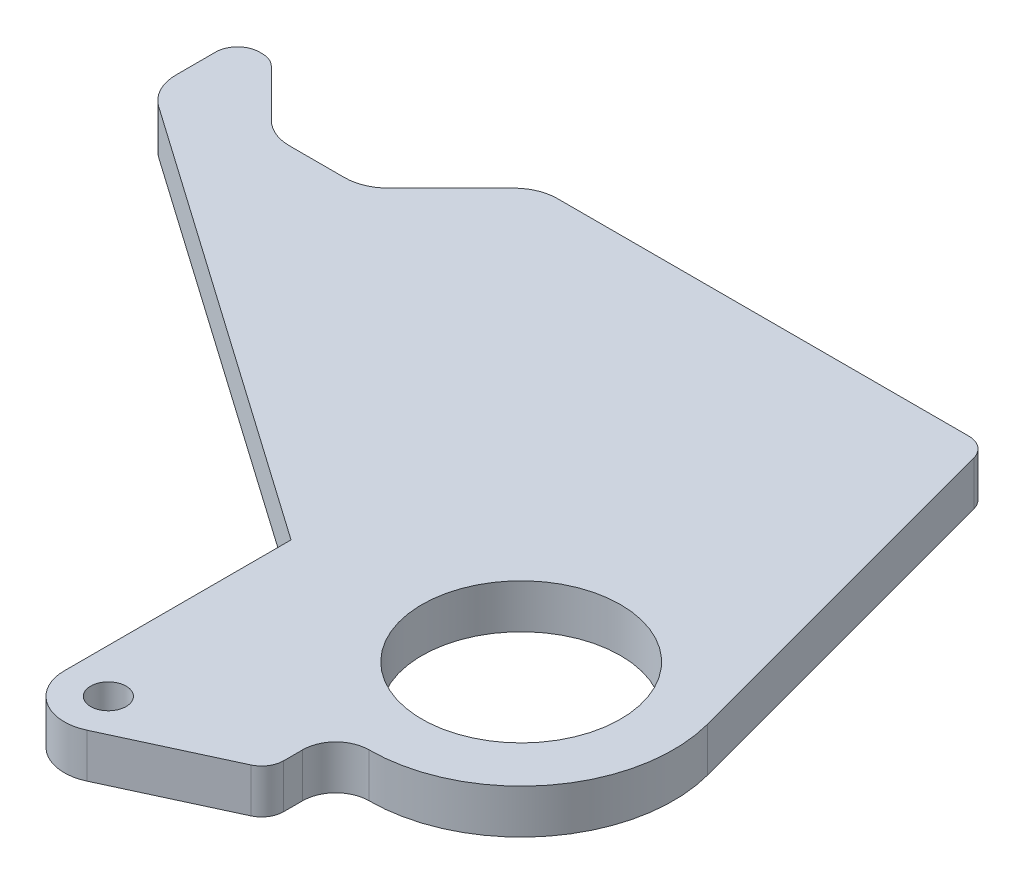
from build123d import *

# Parameters (mm, degrees)
SKETCH1_R           = 2.5527
SKETCH1_R_2         = 14.2875
BOSS_EXTRUDE1_DEPTH = 6.35


with BuildPart() as part:
    # Sketch1 → Boss-Extrude1 (new body)
    with BuildSketch(Plane(origin=(0, 0, 0), x_dir=(1, 0, 0), z_dir=(0, 1, 0))):
        with BuildLine():
            Line((4.080014702, -3.175), (-55.087853576, -3.175))
            ThreePointArc((-55.087853576, -3.175), (-57.517893372, -3.658364969), (-59.577981637, -5.034871939))
            Line((-59.577981637, -5.034871939), (-68.558237758, -14.015128061))
            ThreePointArc((-68.558237758, -14.015128061), (-70.618326023, -15.391635031), (-73.048365818, -15.875))
            Line((-73.048365818, -15.875), (-80.939134182, -15.875))
            ThreePointArc((-80.939134182, -15.875), (-83.369173977, -15.391635031), (-85.429262242, -14.015128061))
            Line((-85.429262242, -14.015128061), (-92.164454333, -7.27993597))
            ThreePointArc((-92.164454333, -7.27993597), (-93.194498465, -6.591682484), (-94.409518363, -6.35))
            Line((-94.409518363, -6.35), (-94.77375, -6.35))
            ThreePointArc((-94.77375, -6.35), (-97.01881403, -7.27993597), (-97.94875, -9.525))
            Line((-97.94875, -9.525), (-97.94875, -15.200863174))
            ThreePointArc((-97.94875, -15.200863174), (-97.231268791, -18.132966868), (-95.240960371, -20.402478656))
            Line((-95.240960371, -20.402478656), (-31.75, -64.859327715))
            Line((-31.75, -64.859327715), (-31.75, -97.4852))
            ThreePointArc((-31.75, -97.4852), (-28.819730055, -102.835708981), (-22.733323984, -103.248127991))
            Line((-22.733323984, -103.248127991), (-6.604161992, -95.784691086))
            ThreePointArc((-6.604161992, -95.784691086), (-5.26224551, -94.613092118), (-4.7625, -92.903227091))
            Line((-4.7625, -92.903227091), (-4.7625, -90.17))
            ThreePointArc((-4.7625, -90.17), (-3.367596045, -86.802403955), (0, -85.4075))
            ThreePointArc((0, -85.4075), (17.380388302, -76.836441006), (21.161020039, -57.829921769))
            Line((21.161020039, -57.829921769), (7.146829201, -5.528249532))
            ThreePointArc((7.146829201, -5.528249532), (6.012832239, -3.831103145), (4.080014702, -3.175))
        make_face()
        with Locations((-25.4, -97.4852)):
            Circle(SKETCH1_R, mode=Mode.SUBTRACT)
        with Locations((0, -63.5)):
            Circle(SKETCH1_R_2, mode=Mode.SUBTRACT)
    extrude(amount=-BOSS_EXTRUDE1_DEPTH)


solid = part.part
